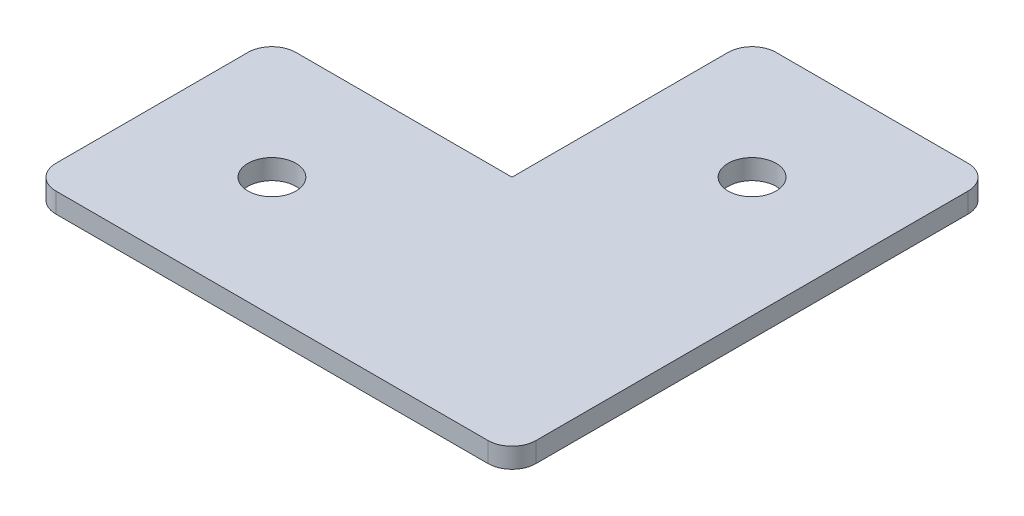
from build123d import *

# Parameters (mm, degrees)
BOSS_EXTRUDE1_DEPTH = 2.5
FILLET1_R           = 3
FILLET2_R           = 3
FILLET3_R           = 3
FILLET4_R           = 3
FILLET5_R           = 3
SKETCH2_R           = 3
CUT_EXTRUDE1_DEPTH  = 3


with BuildPart() as part:
    # Sketch1 → Boss-Extrude1 (new body)
    with BuildSketch(Plane(origin=(0, 0, 0), x_dir=(1, 0, 0), z_dir=(0, 1, 0))):
        Polygon((-12.469879518, 24.84939759), (17.530120482, 24.84939759), (17.530120482, -35.15060241), (-12.469879518, -35.15060241), (-42.469879518, -35.15060241), (-42.469879518, -5.15060241), (-12.469879518, -5.15060241), align=None)
    extrude(amount=BOSS_EXTRUDE1_DEPTH)

    # Fillet1
    fillet1_edges = [part.edges().sort_by_distance(p)[0] for p in [
        (-42.469879518, 1.25, 5.15060241),
    ]]
    fillet(fillet1_edges, radius=FILLET1_R)

    # Fillet2
    fillet2_edges = [part.edges().sort_by_distance(p)[0] for p in [
        (-42.469879518, 1.25, 35.15060241),
    ]]
    fillet(fillet2_edges, radius=FILLET2_R)

    # Fillet3
    fillet3_edges = [part.edges().sort_by_distance(p)[0] for p in [
        (17.530120482, 1.25, 35.15060241),
    ]]
    fillet(fillet3_edges, radius=FILLET3_R)

    # Fillet4
    fillet4_edges = [part.edges().sort_by_distance(p)[0] for p in [
        (17.530120482, 1.25, -24.84939759),
    ]]
    fillet(fillet4_edges, radius=FILLET4_R)

    # Fillet5
    fillet5_edges = [part.edges().sort_by_distance(p)[0] for p in [
        (-12.469879518, 1.25, -24.84939759),
    ]]
    fillet(fillet5_edges, radius=FILLET5_R)

    # Sketch2 → Cut-Extrude1 (cut)
    with BuildSketch(Plane(origin=(0, 2.5, 0), x_dir=(1, 0, 0), z_dir=(0, 1, 0))):
        with Locations((2.530120482, 9.84939759)):
            Circle(SKETCH2_R)
        with Locations((-27.469879518, -20.15060241)):
            Circle(SKETCH2_R)
    extrude(amount=-CUT_EXTRUDE1_DEPTH, mode=Mode.SUBTRACT)


solid = part.part
